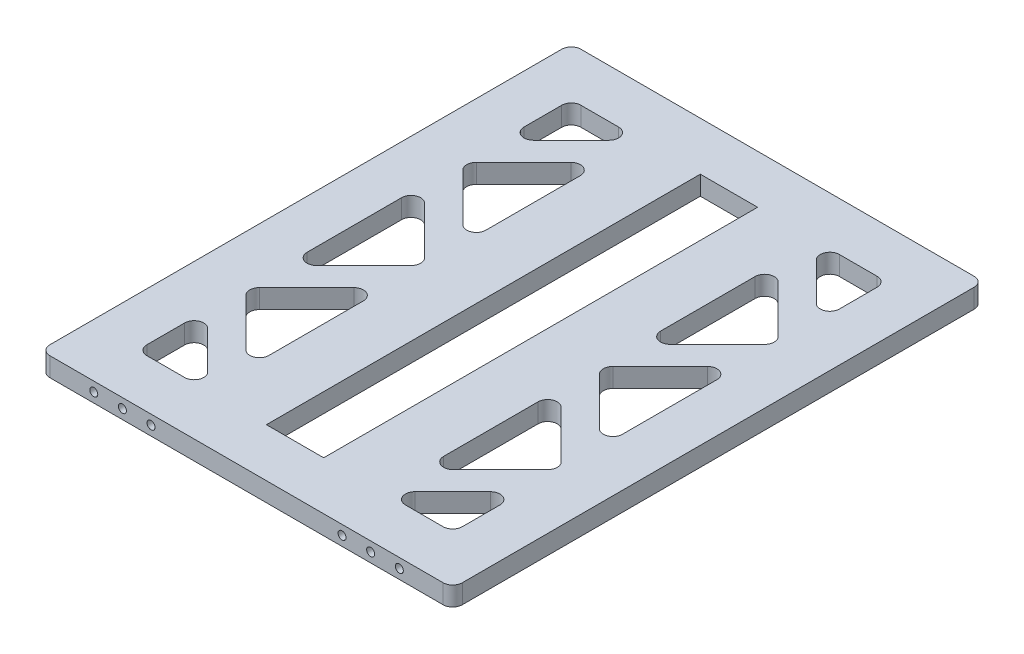
from build123d import *

# Parameters (mm, degrees)
SKETCH1_W                       = 215.9
SKETCH1_H                       = 278
SKETCH1_W_2                     = 30
SKETCH1_H_2                     = 227.2
BOSS_EXTRUDE1_DEPTH             = 5
TAP_DRILL_FOR_M5X0_8_TAP1_D     = 4.2
TAP_DRILL_FOR_M5X0_8_TAP1_DEPTH = 20
TAP_DRILL_FOR_M5X0_8_TAP1_TIP   = 1.2618073
FILLET1_R                       = 5


with BuildPart() as part:
    # Sketch1 → Boss-Extrude1 (new body, symmetric)
    with BuildSketch(Plane(origin=(0, 0, 0), x_dir=(1, 0, 0), z_dir=(0, 1, 0))):
        Rectangle(SKETCH1_W, SKETCH1_H)
        Polygon((-45.75, 113.6), (-82.55, 113.6), (-82.55, 76.8), align=None, mode=Mode.SUBTRACT)
        Rectangle(SKETCH1_W_2, SKETCH1_H_2, mode=Mode.SUBTRACT)
        Polygon((-82.55, 56.8), (-45.75, 93.6), (-45.75, 20), align=None, mode=Mode.SUBTRACT)
        Polygon((-82.55, 36.8), (-45.75, 0), (-82.55, -36.8), align=None, mode=Mode.SUBTRACT)
        Polygon((-82.55, -113.6), (-82.55, -76.8), (-45.75, -113.6), align=None, mode=Mode.SUBTRACT)
        Polygon((-45.75, -93.6), (-45.75, -20), (-82.55, -56.8), align=None, mode=Mode.SUBTRACT)
        Polygon((45.75, -113.6), (82.55, -113.6), (82.55, -76.8), align=None, mode=Mode.SUBTRACT)
        Polygon((82.55, -56.8), (45.75, -93.6), (45.75, -20), align=None, mode=Mode.SUBTRACT)
        Polygon((45.75, 0), (82.55, -36.8), (82.55, 36.8), align=None, mode=Mode.SUBTRACT)
        Polygon((45.75, 93.6), (45.75, 20), (82.55, 56.8), align=None, mode=Mode.SUBTRACT)
        Polygon((82.55, 113.6), (82.55, 76.8), (45.75, 113.6), align=None, mode=Mode.SUBTRACT)
    extrude(amount=BOSS_EXTRUDE1_DEPTH, both=True)

    # Tap Drill for M5x0.8 Tap1
    with Locations(Plane(origin=(-80, 0, 139), x_dir=(1, 0, 0), z_dir=(0, 0, 1))):
        with Locations((0, 0), (15, 0), (30, 0), (130, 0), (145, 0), (160, 0)):
            Hole(TAP_DRILL_FOR_M5X0_8_TAP1_D / 2, depth=TAP_DRILL_FOR_M5X0_8_TAP1_DEPTH)
            with Locations((0, 0, -(TAP_DRILL_FOR_M5X0_8_TAP1_DEPTH + TAP_DRILL_FOR_M5X0_8_TAP1_TIP / 2))):  # 118° drill point
                Cone(0, TAP_DRILL_FOR_M5X0_8_TAP1_D / 2, TAP_DRILL_FOR_M5X0_8_TAP1_TIP, mode=Mode.SUBTRACT)

    # Fillet1
    fillet1_edges = [part.edges().sort_by_distance(p)[0] for p in [
        (45.75, 0, 0),
        (82.55, 0, 36.8),
        (82.55, 0, -56.8),
        (45.75, 0, -93.6),
        (45.75, 0, -20),
        (82.55, 0, -113.6),
        (45.75, 0, -113.6),
        (82.55, 0, -76.8),
        (-82.55, 0, -76.8),
        (-45.75, 0, -113.6),
        (-82.55, 0, -113.6),
        (-82.55, 0, -56.8),
        (-45.75, 0, -20),
        (-45.75, 0, -93.6),
        (-82.55, 0, -36.8),
        (-82.55, 0, 36.8),
        (-45.75, 0, 0),
        (-82.55, 0, 113.6),
        (-45.75, 0, 113.6),
        (-82.55, 0, 76.8),
        (-82.55, 0, 56.8),
        (-45.75, 0, 93.6),
        (-45.75, 0, 20),
        (-107.95, 0, -139),
        (82.55, 0, 76.8),
        (45.75, 0, 113.6),
        (107.95, 0, -139),
        (82.55, 0, 113.6),
        (107.95, 0, 139),
        (-107.95, 0, 139),
        (82.55, 0, 56.8),
        (45.75, 0, 20),
        (45.75, 0, 93.6),
        (82.55, 0, -36.8),
    ]]
    fillet(fillet1_edges, radius=FILLET1_R)


solid = part.part
